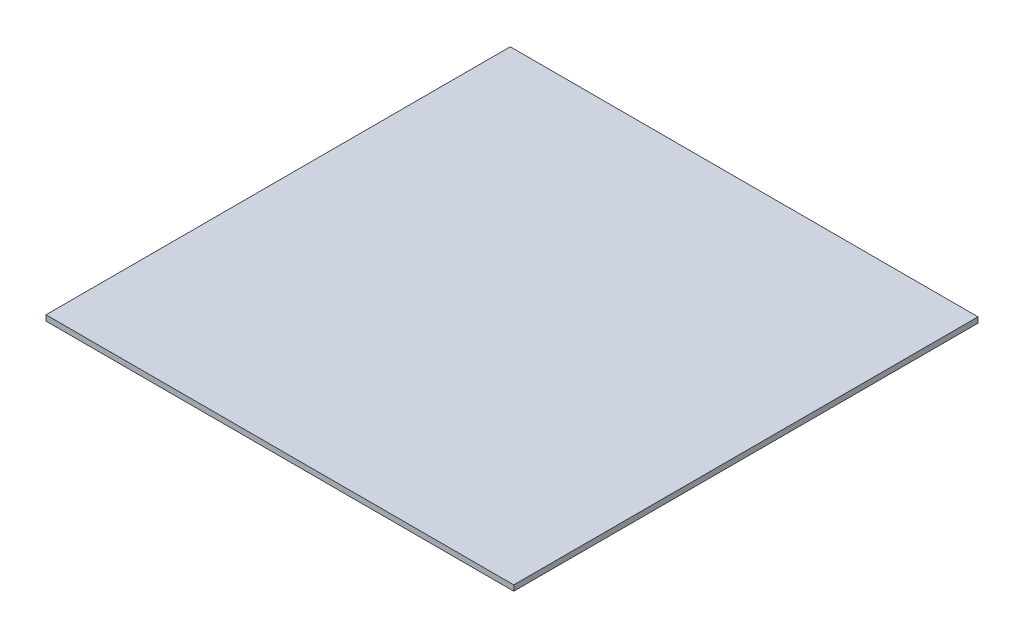
from build123d import *

# Parameters (mm, degrees)
SKETCH1_W           = 134.366
SKETCH1_H           = 133.35
BOSS_EXTRUDE1_DEPTH = 1.5875


with BuildPart() as part:
    # Sketch1 → Boss-Extrude1 (new body)
    with BuildSketch(Plane(origin=(0, 0, 0), x_dir=(1, 0, 0), z_dir=(0, 1, 0))):
        with Locations((67.183, 66.675)):
            Rectangle(SKETCH1_W, SKETCH1_H)
    extrude(amount=BOSS_EXTRUDE1_DEPTH)


solid = part.part
